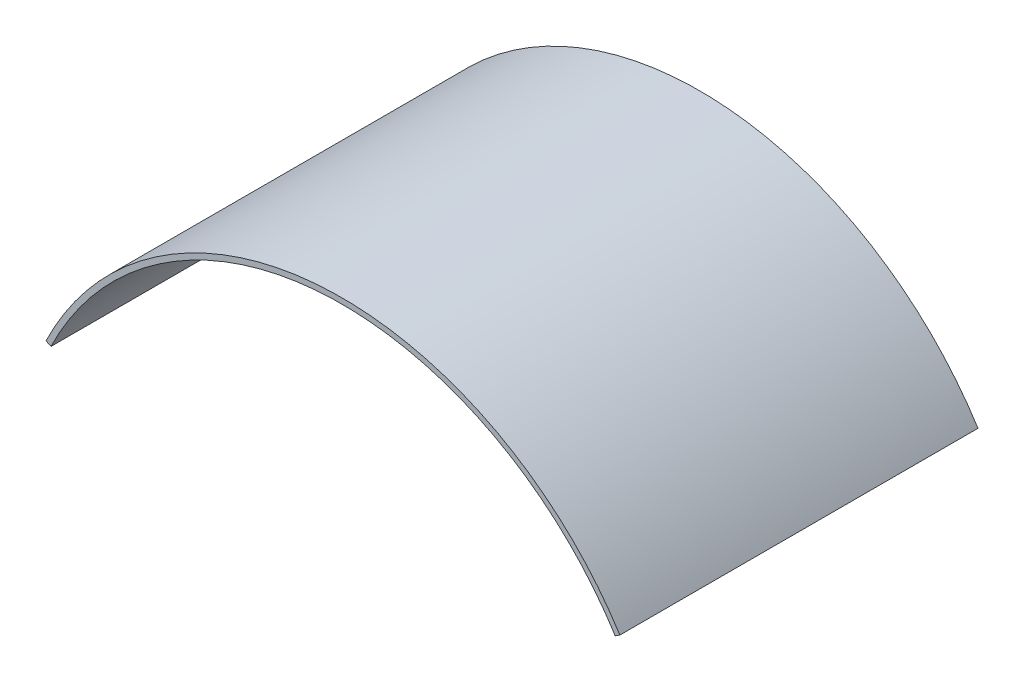
from build123d import *

# Parameters (mm, degrees)
BOSS_EXTRUDE1_DEPTH = 113.5


with BuildPart() as part:
    # Sketch1 → Boss-Extrude1 (new body)
    with BuildSketch(Plane.XY):
        with BuildLine():
            Line((0, 0), (1.574318546, -0.764212743))
            ThreePointArc((1.574318546, -0.764212743), (88.041544603, 56.800277526), (180.385680751, 9.231251459))
            Line((180.385680751, 9.231251459), (181.865019166, 10.166162073))
            ThreePointArc((181.865019166, 10.166162073), (87.943872974, 58.547549758), (0, 0))
        make_face()
    extrude(amount=BOSS_EXTRUDE1_DEPTH)


solid = part.part
